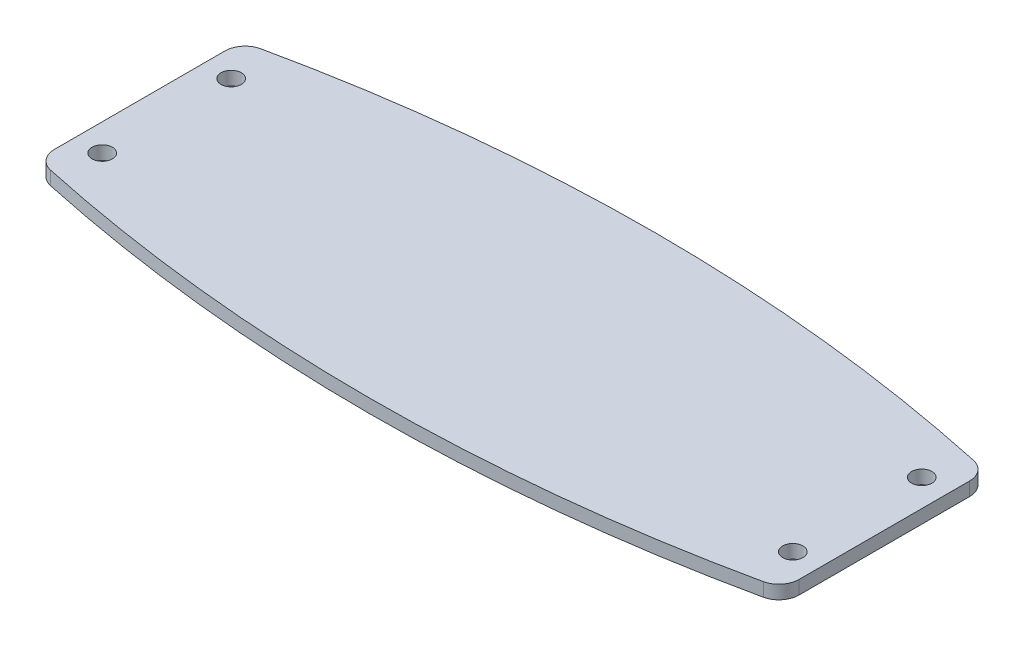
from build123d import *

# Parameters (mm, degrees)
SKETCH_1_R      = 1.5
EXTRUDE_1_DEPTH = 2


with BuildPart() as part:
    # Эскиз1 → Бобышка-Вытянуть1 (new body)
    with BuildSketch(Plane(origin=(0, 0, 0), x_dir=(1, 0, 0), z_dir=(0, 1, 0))):
        with BuildLine():
            Line((-55, -2.410684892), (-55, -27.589315108))
            ThreePointArc((-55, -27.589315108), (-54.333959816, -29.474157695), (-52.631578947, -30.52207968))
            ThreePointArc((-52.631578947, -30.52207968), (0, -36.125032035), (52.631578947, -30.52207968))
            ThreePointArc((52.631578947, -30.52207968), (54.333959816, -29.474157695), (55, -27.589315108))
            Line((55, -27.589315108), (55, -2.410684892))
            ThreePointArc((55, -2.410684892), (54.333959816, -0.525842305), (52.631578947, 0.52207968))
            ThreePointArc((52.631578947, 0.52207968), (0, 6.125032035), (-52.631578947, 0.52207968))
            ThreePointArc((-52.631578947, 0.52207968), (-54.333959816, -0.525842305), (-55, -2.410684892))
        make_face()
        with Locations((-51, -5.47792032)):
            Circle(SKETCH_1_R, mode=Mode.SUBTRACT)
        with Locations((-51, -24.52207968)):
            Circle(SKETCH_1_R, mode=Mode.SUBTRACT)
        with Locations((51, -5.47792032)):
            Circle(SKETCH_1_R, mode=Mode.SUBTRACT)
        with Locations((51, -24.52207968)):
            Circle(SKETCH_1_R, mode=Mode.SUBTRACT)
    extrude(amount=EXTRUDE_1_DEPTH)


solid = part.part
